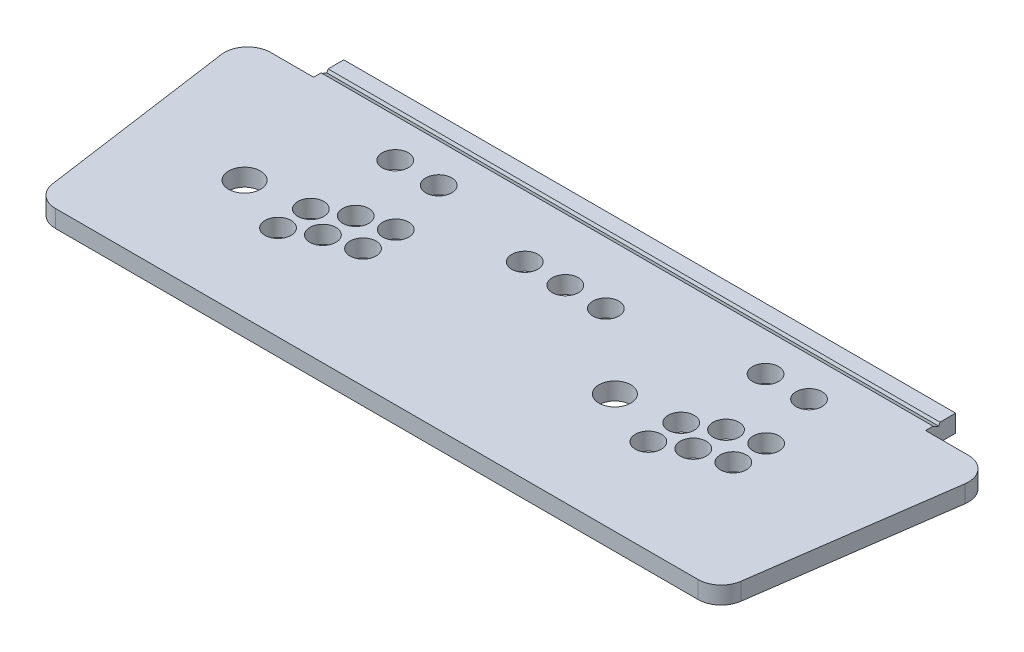
from build123d import *

# Parameters (mm, degrees)
SKETCH1_W               = 671.5125
SKETCH1_H               = 299.466
BOSS_EXTRUDE1_DEPTH     = 9.525
BOSS_EXTRUDE2_DEPTH     = 19.05
FILLET1_R               = 25.4
SKETCH3_R               = 17.5
SKETCH3_R_2             = 14.2875
CUT_EXTRUDE1_DEPTH      = 1
CUT_EXTRUDE1_DEPTH_BACK = 20.05
CUT_EXTRUDE2_DEPTH      = 7.9375
CUT_EXTRUDE3_DEPTH      = 409.263892457
CUT_EXTRUDE3_DEPTH_BACK = 409.263892457
CUT_EXTRUDE5_START      = -19.05
SKETCH3_3_R             = 3.96875
CUT_EXTRUDE5_DEPTH      = 11.1125
SKETCH8_R               = 5.953125
CUT_EXTRUDE6_DEPTH      = 1.016


with BuildPart() as part:
    # Sketch1 → Boss-Extrude1 (new body, symmetric)
    with BuildSketch(Plane(origin=(0, 0, 0), x_dir=(1, 0, 0), z_dir=(0, 1, 0))):
        Rectangle(SKETCH1_W, SKETCH1_H)
    extrude(amount=BOSS_EXTRUDE1_DEPTH, both=True)

    # Sketch2 → Boss-Extrude2 (add)
    with BuildSketch(Plane(origin=(0, 9.525, 0), x_dir=(1, 0, 0), z_dir=(0, 1, 0))):
        Polygon((335.75625, -149.733), (374.643853371, -149.733), (412.08325, 116.6621492), (335.75625, 116.6621492), align=None)
        Polygon((-335.75625, 116.6621492), (-335.75625, -149.733), (-374.643853371, -149.733), (-412.08325, 116.6621492), align=None)
    extrude(amount=-BOSS_EXTRUDE2_DEPTH)

    # Fillet1
    fillet1_edges = [part.edges().sort_by_distance(p)[0] for p in [
        (374.643853371, 0, 149.733),
        (412.08325, 0, -116.6621492),
        (-412.08325, 0, -116.6621492),
        (-374.643853371, 0, 149.733),
    ]]
    fillet(fillet1_edges, radius=FILLET1_R)

    # Sketch3 → Cut-Extrude1 (cut, two sides)
    with BuildSketch(Plane(origin=(0, 9.525, 0), x_dir=(1, 0, 0), z_dir=(0, 1, 0))) as cut_extrude1_sk:
        with Locations((-275.836957508, -19.05)):
            Circle(SKETCH3_R)
        with Locations((-180.836957508, 7.95)):
            Circle(SKETCH3_R_2)
        with Locations((-145.836957508, 16.95)):
            Circle(SKETCH3_R_2)
        with Locations((-145.836957508, -19.05)):
            Circle(SKETCH3_R_2)
        with Locations((-180.836957508, -28.05)):
            Circle(SKETCH3_R_2)
        with Locations((-212.086957508, -10.05)):
            Circle(SKETCH3_R_2)
        with Locations((-212.086957508, -46.05)):
            Circle(SKETCH3_R_2)
        with Locations((-212.086957508, 82.55)):
            Circle(SKETCH3_R_2)
        with Locations((-164.36967051, 82.55)):
            Circle(SKETCH3_R_2)
        with Locations((130.563042492, -19.05)):
            Circle(SKETCH3_R)
        with Locations((225.563042492, 7.95)):
            Circle(SKETCH3_R_2)
        with Locations((260.563042492, 16.95)):
            Circle(SKETCH3_R_2)
        with Locations((260.563042492, -19.05)):
            Circle(SKETCH3_R_2)
        with Locations((225.563042492, -28.05)):
            Circle(SKETCH3_R_2)
        with Locations((194.313042492, -10.05)):
            Circle(SKETCH3_R_2)
        with Locations((194.313042492, -46.05)):
            Circle(SKETCH3_R_2)
        with Locations((194.313042492, 82.55)):
            Circle(SKETCH3_R_2)
        with Locations((242.03032949, 82.55)):
            Circle(SKETCH3_R_2)
        with Locations((-44.45, 57.15)):
            Circle(SKETCH3_R_2)
        with Locations((0, 57.15)):
            Circle(SKETCH3_R_2)
        with Locations((44.45, 57.15)):
            Circle(SKETCH3_R_2)
    extrude(amount=CUT_EXTRUDE1_DEPTH, mode=Mode.SUBTRACT)
    extrude(cut_extrude1_sk.sketch, amount=-CUT_EXTRUDE1_DEPTH_BACK, mode=Mode.SUBTRACT)

    # Sketch4 → Cut-Extrude2 (cut)
    with BuildSketch(Plane.XZ.offset(9.525)):
        with BuildLine():
            Line((-355.727, -48.520132908), (-355.727, 91.179867092))
            ThreePointArc((-355.727, 91.179867092), (-346.075, 100.831867092), (-336.423, 91.179867092))
            Line((-336.423, 91.179867092), (-336.423, -48.520132908))
            ThreePointArc((-336.423, -48.520132908), (-346.075, -58.172132908), (-355.727, -48.520132908))
        make_face()
        with BuildLine():
            Line((355.727, -48.520132908), (355.727, 91.179867092))
            ThreePointArc((355.727, 91.179867092), (346.075, 100.831867092), (336.423, 91.179867092))
            Line((336.423, 91.179867092), (336.423, -48.520132908))
            ThreePointArc((336.423, -48.520132908), (346.075, -58.172132908), (355.727, -48.520132908))
        make_face()
    extrude(amount=-CUT_EXTRUDE2_DEPTH, mode=Mode.SUBTRACT)

    # Sketch5 → Cut-Extrude3 (cut, two sides)
    with BuildSketch(Plane(origin=(0, 0, 0), x_dir=(0, 0, -1), z_dir=(1, 0, 0))) as cut_extrude3_sk:
        Polygon((132.550024206, 9.525), (131.232981568, 6.35), (124.767204191, 9.032111651), (126.084246829, 12.207111651), align=None)
    extrude(amount=CUT_EXTRUDE3_DEPTH, mode=Mode.SUBTRACT)
    extrude(cut_extrude3_sk.sketch, amount=-CUT_EXTRUDE3_DEPTH_BACK, mode=Mode.SUBTRACT)

    # Sketch3_3 → Cut-Extrude5 (cut)
    with BuildSketch(Plane(origin=(0, 9.525, 0), x_dir=(1, 0, 0), z_dir=(0, 1, 0)).offset(CUT_EXTRUDE5_START)):
        with Locations((-308.636957508, 18.9)):
            Circle(SKETCH3_3_R)
        with Locations((-243.036957508, 18.9)):
            Circle(SKETCH3_3_R)
        with Locations((-308.636957508, -57)):
            Circle(SKETCH3_3_R)
        with Locations((-243.036957508, -57)):
            Circle(SKETCH3_3_R)
        with Locations((97.763042492, 18.9)):
            Circle(SKETCH3_3_R)
        with Locations((163.363042492, 18.9)):
            Circle(SKETCH3_3_R)
        with Locations((97.763042492, -57)):
            Circle(SKETCH3_3_R)
        with Locations((163.363042492, -57)):
            Circle(SKETCH3_3_R)
    extrude(amount=CUT_EXTRUDE5_DEPTH, mode=Mode.SUBTRACT)

    # Sketch8 → Cut-Extrude6 (cut)
    with BuildSketch(Plane.XZ.offset(9.525)):
        with Locations((163.363042492, -18.9)):
            Circle(SKETCH8_R)
        with Locations((163.363042492, 57)):
            Circle(SKETCH8_R)
        with Locations((97.763042492, 57)):
            Circle(SKETCH8_R)
        with Locations((97.763042492, -18.9)):
            Circle(SKETCH8_R)
        with Locations((-243.036957508, -18.9)):
            Circle(SKETCH8_R)
        with Locations((-243.036957508, 57)):
            Circle(SKETCH8_R)
        with Locations((-308.636957508, 57)):
            Circle(SKETCH8_R)
        with Locations((-308.636957508, -18.9)):
            Circle(SKETCH8_R)
    extrude(amount=-CUT_EXTRUDE6_DEPTH, mode=Mode.SUBTRACT)


solid = part.part
